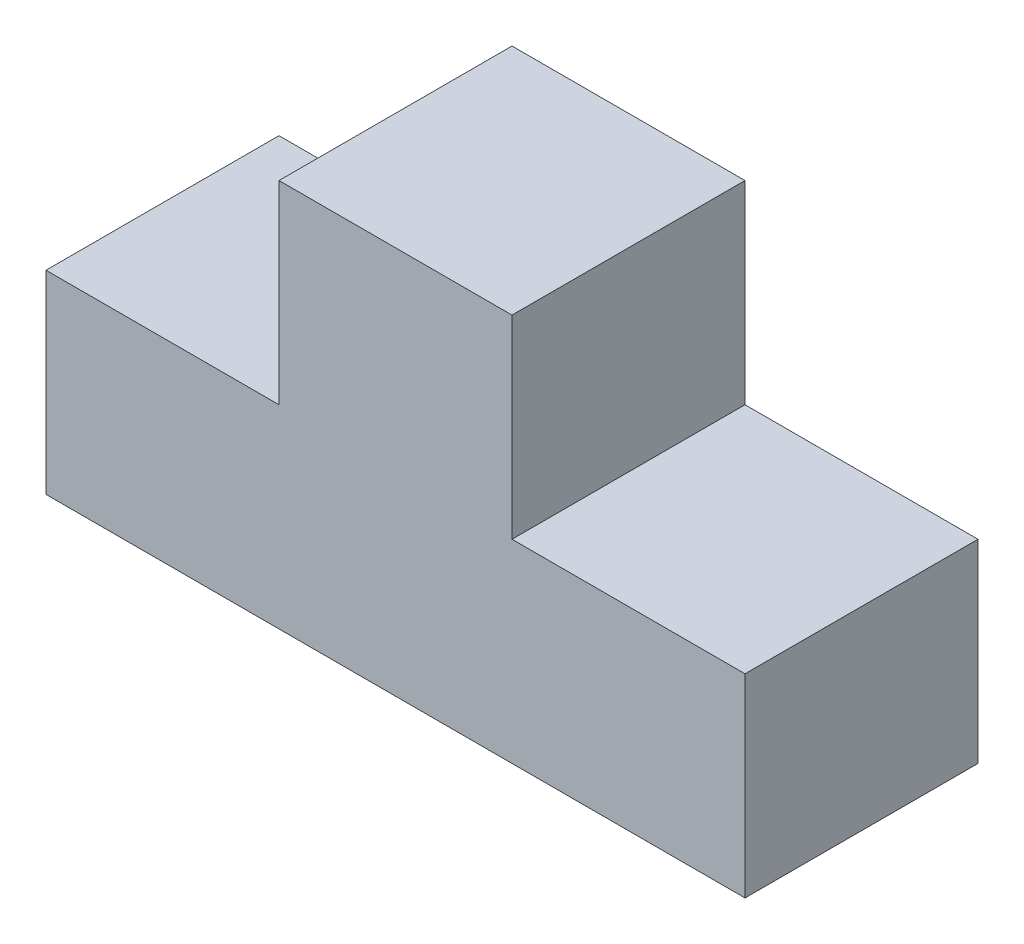
from build123d import *

# Parameters (mm, degrees)
BOSS_EXTRUDE1_DEPTH = 30


with BuildPart() as part:
    # Sketch2 → Boss-Extrude1 (new body)
    with BuildSketch(Plane.XY):
        Polygon((-45, 0), (45, 0), (45, 25), (15, 25), (15, 50), (-15, 50), (-15, 25), (-45, 25), align=None)
    extrude(amount=BOSS_EXTRUDE1_DEPTH)


solid = part.part
